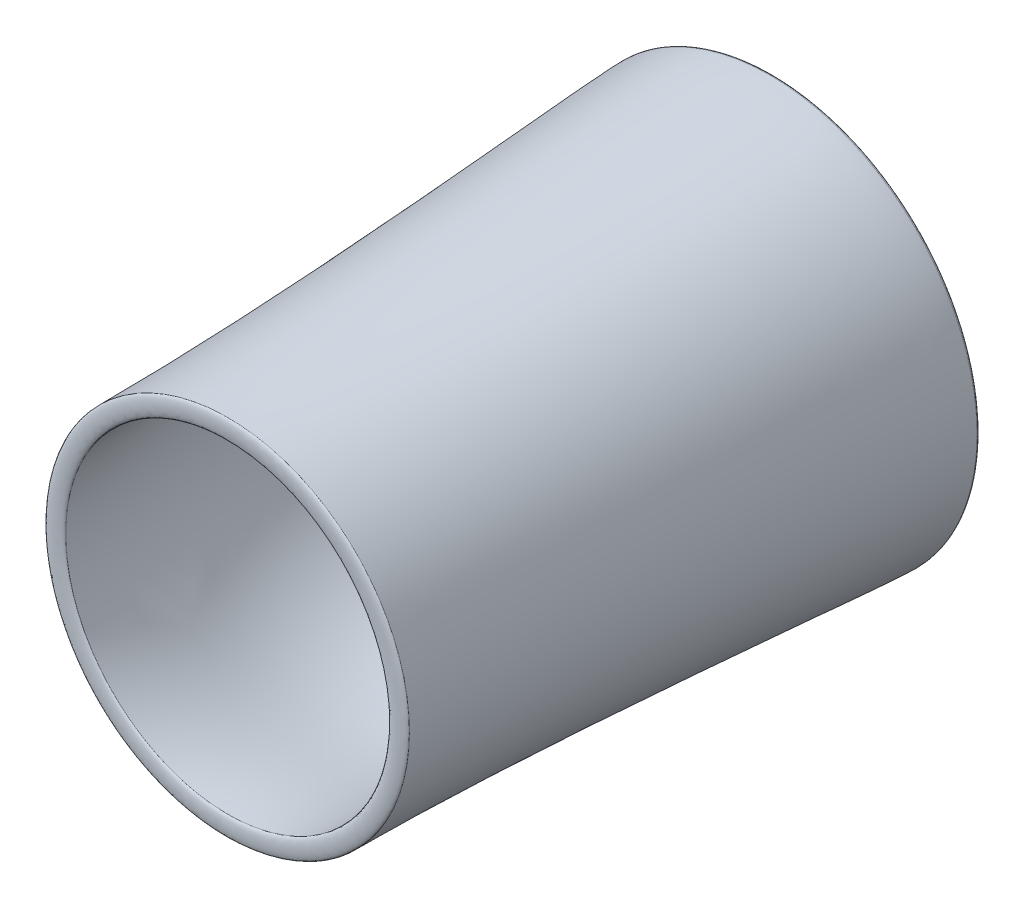
from build123d import *


with BuildPart() as part:
    # Sketch21 → Revolve2 (revolve)
    with BuildSketch(Plane(origin=(0, 0, 0), x_dir=(1, 0, 0), z_dir=(0, 1, 0))):
        with BuildLine():
            Line((-556.631697094, -1297.822140602), (-623.081922495, -1297.822140602))
            add(Edge.make_bspline(
                [(-711.609923736, 561.878149911), (-711.609923736, 436.494197534), (-623.081922495, -567.513020217), (-623.081922495, -1297.822140602)],
                knots=[0, 0, 0, 0, 1, 1, 1, 1], degree=3))
            Line((-711.609923736, 561.878149911), (-663.065581116, 561.878149911))
            add(Edge.make_bspline(
                [(-663.065581116, 561.878149911), (-663.065581116, 509.242397389), (-605.315551479, 116.420781355), (-570.360209306, -82.555379778), (-651.10860042, -812.70610931), (-556.631697094, -1008.713519962), (-556.631697094, -1297.822140602)],
                knots=[0, 0, 0, 0, 0.158009172, 0.206506907, 0.484977351, 1, 1, 1, 1], degree=3))
        make_face()
    revolve(axis=Axis((0, 0, 99.684784321), (0, 0, -1)))


with BuildPart() as body_2:
    # Sketch22 → Revolve3 (revolve)
    with BuildSketch(Plane(origin=(0, 0, 0), x_dir=(1, 0, 0), z_dir=(0, 1, 0))):
        with BuildLine():
            Line((-711.609923736, 561.878149911), (-663.065581116, 561.878149911))
            add(Edge.make_bspline(
                [(-711.609923736, 561.878149911), (-711.609923736, 578.811483244), (-663.065581116, 578.811483244), (-663.065581116, 561.878149911)],
                knots=[0, 0, 0, 0, 1, 1, 1, 1], degree=3))
        make_face()
    revolve(axis=Axis((0, 0, 99.684784321), (0, 0, -1)))


with BuildPart() as body_3:
    # Sketch23 → Revolve4 (revolve)
    with BuildSketch(Plane(origin=(0, 0, 0), x_dir=(1, 0, 0), z_dir=(0, 1, 0))):
        with BuildLine():
            Line((-623.081922495, -1297.822140602), (-556.631697094, -1297.822140602))
            add(Edge.make_bspline(
                [(-623.081922495, -1297.822140602), (-623.081922495, -1310.522140602), (-556.631697094, -1310.522140602), (-556.631697094, -1297.822140602)],
                knots=[0, 0, 0, 0, 1, 1, 1, 1], degree=3))
        make_face()
    revolve(axis=Axis((0, 0, 1104.756830123), (0, 0, -1)))


solid = Compound([part.part, body_2.part, body_3.part])
